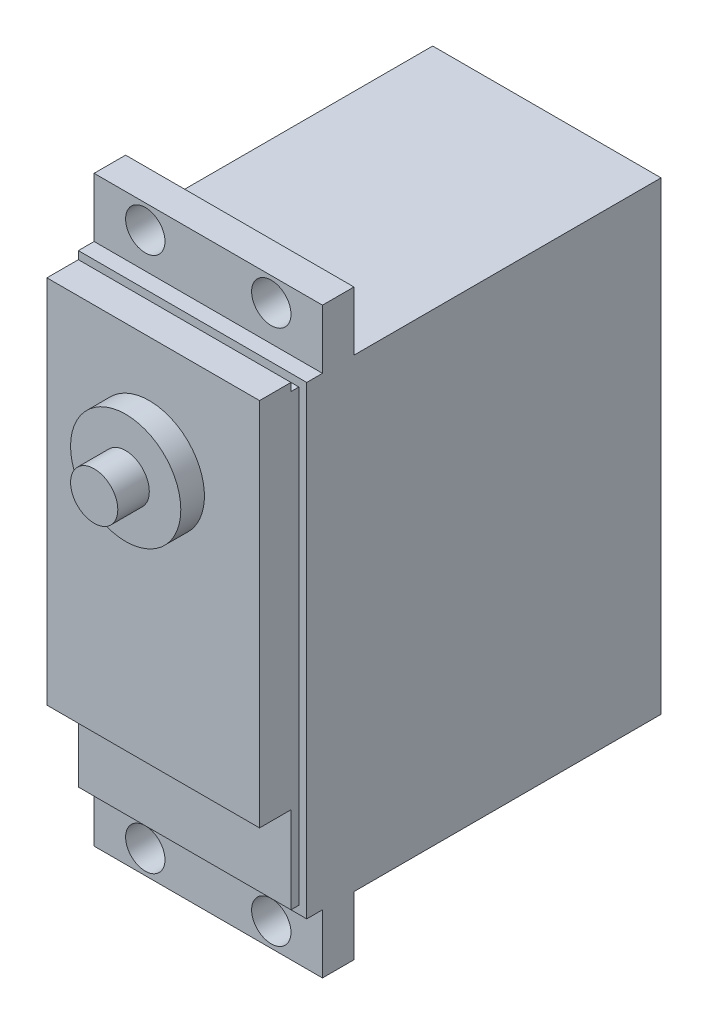
from build123d import *

# Parameters (mm, degrees)
SKETCH4_W           = 29
SKETCH4_H           = 59
BOSS_EXTRUDE2_DEPTH = 43
SKETCH5_W           = 29
SKETCH5_H           = 74
BOSS_EXTRUDE3_DEPTH = 4
SKETCH6_W           = 29
SKETCH6_H           = 59
BOSS_EXTRUDE4_DEPTH = 2
SKETCH7_W           = 27
SKETCH7_H           = 57
BOSS_EXTRUDE5_DEPTH = 1
SKETCH8_W           = 27
SKETCH8_H           = 47
BOSS_EXTRUDE7_DEPTH = 3.99
SKETCH11_R          = 7
BOSS_EXTRUDE8_DEPTH = 3
SKETCH12_R          = 3
BOSS_EXTRUDE9_DEPTH = 4
SKETCH13_R          = 2.5
CUT_EXTRUDE1_DEPTH  = 4


with BuildPart() as part:
    # Sketch4 → Boss-Extrude2 (new body)
    with BuildSketch(Plane.XY):
        with Locations((-44.629997068, -10.100928214)):
            Rectangle(SKETCH4_W, SKETCH4_H)
    extrude(amount=BOSS_EXTRUDE2_DEPTH)

    # Sketch5 → Boss-Extrude3 (add)
    with BuildSketch(Plane.XY.offset(43)):
        with Locations((-44.629997068, -10.100928214)):
            Rectangle(SKETCH5_W, SKETCH5_H)
    extrude(amount=-BOSS_EXTRUDE3_DEPTH)

    # Sketch6 → Boss-Extrude4 (add)
    with BuildSketch(Plane.XY.offset(43)):
        with Locations((-44.629997068, -10.100928214)):
            Rectangle(SKETCH6_W, SKETCH6_H)
    extrude(amount=BOSS_EXTRUDE4_DEPTH)

    # Sketch7 → Boss-Extrude5 (add)
    with BuildSketch(Plane.XY.offset(45)):
        with Locations((-44.629997068, -10.100928214)):
            Rectangle(SKETCH7_W, SKETCH7_H)
    extrude(amount=BOSS_EXTRUDE5_DEPTH)

    # Sketch8 → Boss-Extrude7 (add)
    with BuildSketch(Plane.XY.offset(46)):
        with Locations((-44.629997068, -4.100928214)):
            Rectangle(SKETCH8_W, SKETCH8_H)
    extrude(amount=BOSS_EXTRUDE7_DEPTH)

    # Sketch11 → Boss-Extrude8 (add)
    with BuildSketch(Plane.XY.offset(49.99)):
        with Locations((-45.129997068, 5.399071786)):
            Circle(SKETCH11_R)
    extrude(amount=BOSS_EXTRUDE8_DEPTH)

    # Sketch12 → Boss-Extrude9 (add)
    with BuildSketch(Plane.XY.offset(52.99)):
        with Locations((-45.129997068, 5.399071786)):
            Circle(SKETCH12_R)
    extrude(amount=BOSS_EXTRUDE9_DEPTH)

    # Sketch13 → Cut-Extrude1 (cut)
    with BuildSketch(Plane.XY.offset(43)):
        with Locations((-36.629997068, 23.899071786)):
            Circle(SKETCH13_R)
        with Locations((-52.629997068, 23.899071786)):
            Circle(SKETCH13_R)
        with Locations((-52.629997068, -44.100928214)):
            Circle(SKETCH13_R)
        with Locations((-36.629997068, -44.100928214)):
            Circle(SKETCH13_R)
    extrude(amount=-CUT_EXTRUDE1_DEPTH, mode=Mode.SUBTRACT)


solid = part.part
